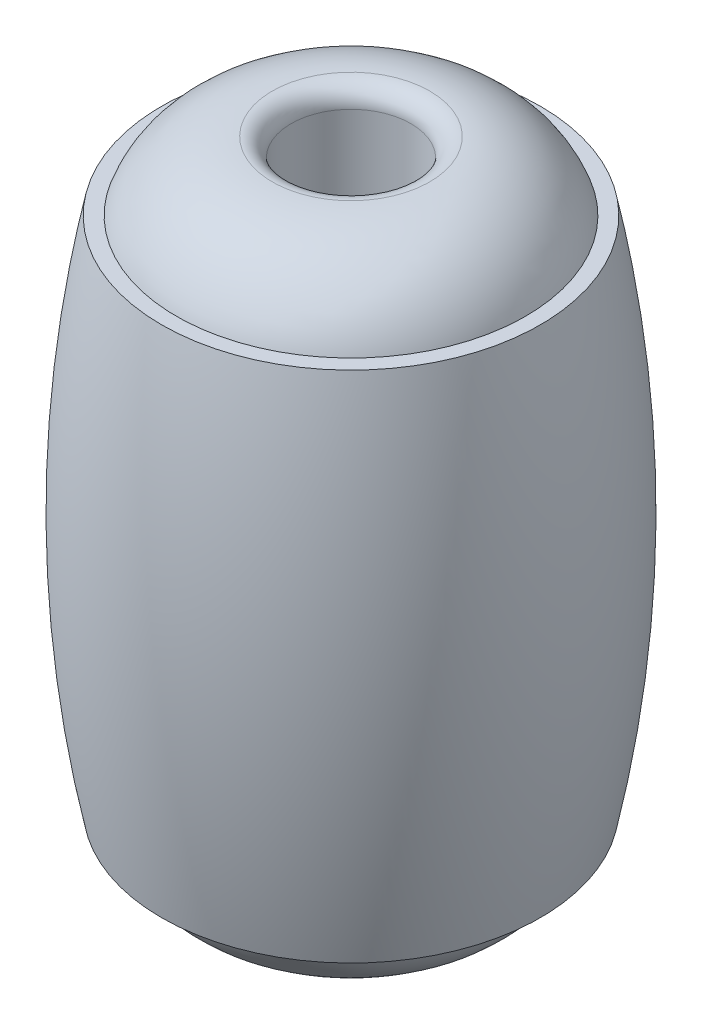
from build123d import *


with BuildPart() as part:
    # Sketch1 → Revolve1 (revolve)
    with BuildSketch(Plane.XY):
        with BuildLine():
            Line((1.75, 0), (6.3, 0))
            ThreePointArc((6.3, 0), (6.107472102, 3.769615029), (5.531892029, 7.5))
            Line((5.531892029, 7.5), (5.1, 7.5))
            ThreePointArc((5.1, 7.5), (4.020465053, 8.948651075), (2.3, 9.5))
            ThreePointArc((2.3, 9.5), (1.91109127, 9.33890873), (1.75, 8.95))
            Line((1.75, 8.95), (1.75, 0))
        make_face()
    revolve1 = revolve(axis=Axis((0, 0, 0), (0, 1, 0)))

    # Mirror1: Revolve1 across plane
    add(revolve1.mirror(Plane(origin=(1.75, 0, 0), x_dir=(0, 0, 1), z_dir=(0, -1, 0))))


solid = part.part
